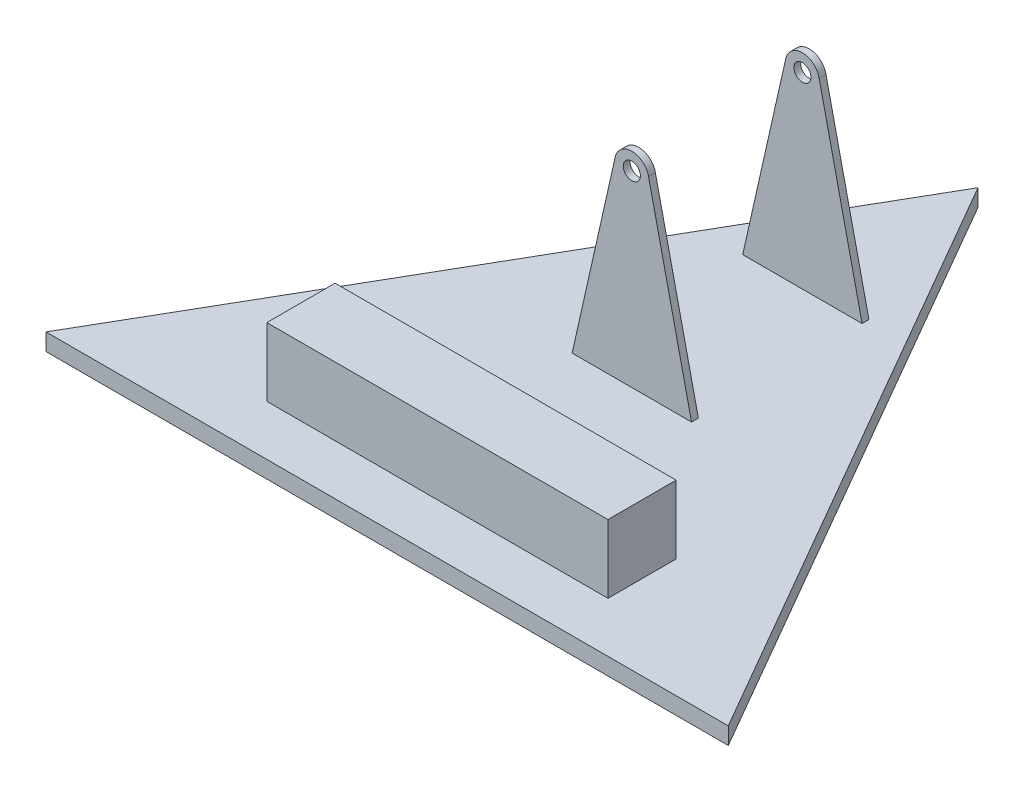
from build123d import *

# Parameters (mm, degrees)
BOSS_EXTRUDE1_DEPTH = 5
SKETCH2_W           = 35
SKETCH2_H           = 2
BOSS_EXTRUDE2_DEPTH = 60
CUT_EXTRUDE1_DEPTH  = 60
SKETCH4_R           = 2.5
CUT_EXTRUDE2_DEPTH  = 60
SKETCH5_W           = 100
SKETCH5_H           = 20
BOSS_EXTRUDE3_DEPTH = 20


with BuildPart() as part:
    # Sketch1 → Boss-Extrude1 (new body)
    with BuildSketch(Plane(origin=(0, 0, 0), x_dir=(1, 0, 0), z_dir=(0, 1, 0))):
        Polygon((0, 115.470053838), (-100, -57.735026919), (100, -57.735026919), align=None)
    extrude(amount=BOSS_EXTRUDE1_DEPTH)

    # Sketch2 → Boss-Extrude2 (add)
    with BuildSketch(Plane(origin=(0, 5, 0), x_dir=(1, 0, 0), z_dir=(0, 1, 0))):
        with Locations((0, 65)):
            Rectangle(SKETCH2_W, SKETCH2_H)
        with Locations((0, 15)):
            Rectangle(SKETCH2_W, SKETCH2_H)
    extrude(amount=BOSS_EXTRUDE2_DEPTH)

    # Sketch3 → Cut-Extrude1 (cut)
    with BuildSketch(Plane.XY.offset(-14)):
        with BuildLine():
            Line((-17.5, 65), (-17.5, 5))
            Line((-17.5, 5), (-4.898590768, 61.001902433))
            ThreePointArc((-4.898590768, 61.001902433), (-4.878030477, 61.097642323), (-4.855599196, 61.192961208))
            ThreePointArc((-4.855599196, 61.192961208), (-3.085060288, 63.934768484), (0, 65))
            Line((0, 65), (-17.5, 65))
        make_face()
        with BuildLine():
            Line((17.5, 65), (0, 65))
            ThreePointArc((0, 65), (3.085060288, 63.934768484), (4.855599196, 61.192961208))
            ThreePointArc((4.855599196, 61.192961208), (4.878030477, 61.097642323), (4.898590768, 61.001902433))
            Line((4.898590768, 61.001902433), (17.5, 5))
            Line((17.5, 5), (17.5, 65))
        make_face()
    extrude(amount=-CUT_EXTRUDE1_DEPTH, mode=Mode.SUBTRACT)

    # Sketch4 → Cut-Extrude2 (cut)
    with BuildSketch(Plane.XY.offset(-14)):
        with Locations((0, 60)):
            Circle(SKETCH4_R)
    extrude(amount=-CUT_EXTRUDE2_DEPTH, mode=Mode.SUBTRACT)

    # Sketch5 → Boss-Extrude3 (add)
    with BuildSketch(Plane(origin=(0, 5, 0), x_dir=(1, 0, 0), z_dir=(0, 1, 0))):
        with Locations((0, -33)):
            Rectangle(SKETCH5_W, SKETCH5_H)
    extrude(amount=BOSS_EXTRUDE3_DEPTH)


solid = part.part
